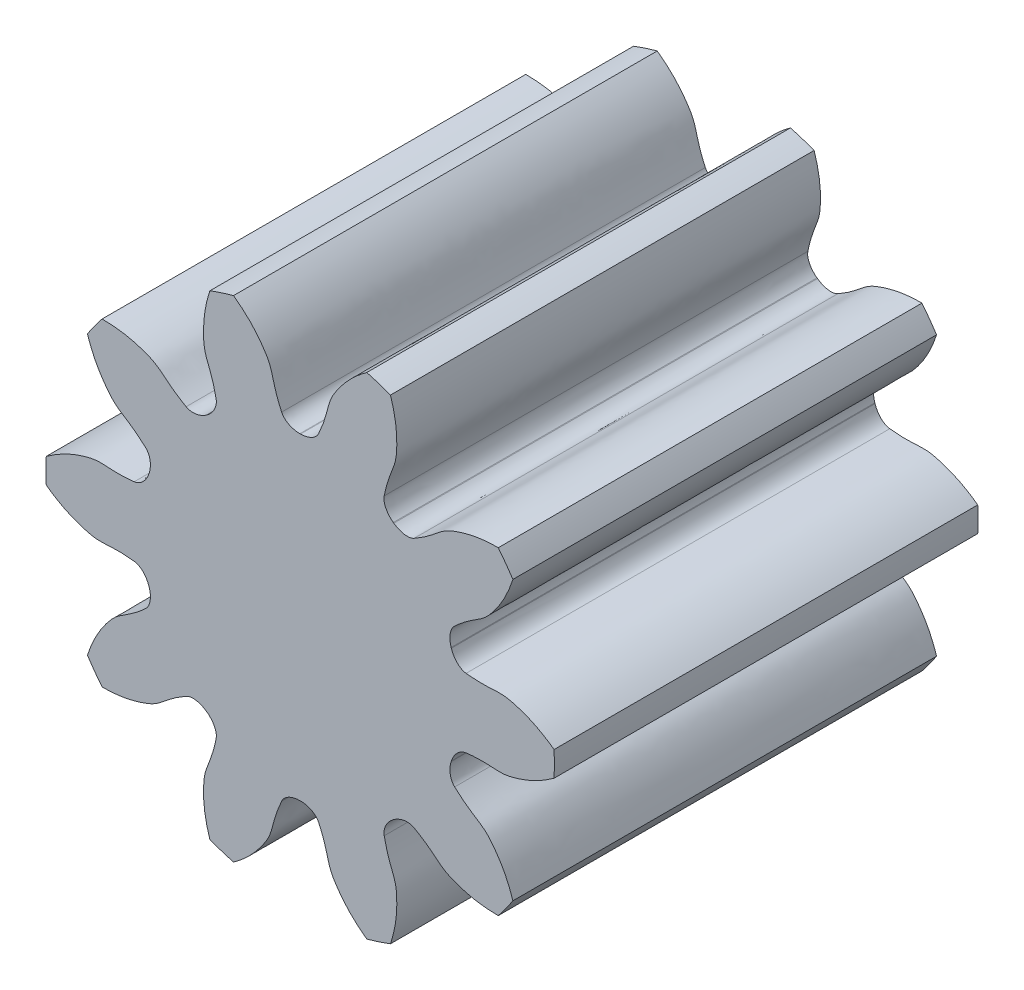
from build123d import *

# Parameters (mm, degrees)
ESQUISSE1_R         = 2.4
BOSS_EXTRU_1_DEPTH  = 4
CREUX_DE_DENT_DEPTH = 4
DENTURE_COUNT       = 10


with BuildPart() as part:
    # Esquisse1 → Boss.-Extru.1 (new body)
    with BuildSketch(Plane.XY):
        Circle(ESQUISSE1_R)
    extrude(amount=BOSS_EXTRU_1_DEPTH)

    # Profil dent → Creux de dent (cut)
    with BuildSketch(Plane.XY.offset(4)):
        with BuildLine():
            ThreePointArc((0.00314159, 1.49999671), (0, 1.5), (-0.00314159, 1.49999671))
            add(Edge.make_bspline(
                [(-0.174783658, 1.590424683), (-0.146609107, 1.530004164), (-0.069808111, 1.499857084), (-0.00314159, 1.49999671)],
                knots=[0, 0, 0, 0, 1, 1, 1, 1], degree=3))
            add(Edge.make_bspline(
                [(-0.649791541, 2.331130831), (-0.577205252, 2.279286461), (-0.456857798, 2.182492765), (-0.307065131, 1.979604877), (-0.262365622, 1.862358121), (-0.23113276, 1.711265721), (-0.174783658, 1.590424683)],
                knots=[0, 0, 0, 0, 0.31446368, 0.566482113, 0.749017728, 1, 1, 1, 1], degree=3))
            ThreePointArc((-0.649791541, 2.331130831), (0, 2.42), (0.649791541, 2.331130831))
            add(Edge.make_bspline(
                [(0.649791541, 2.331130831), (0.577205252, 2.279286461), (0.456857798, 2.182492765), (0.307065131, 1.979604877), (0.262365622, 1.862358121), (0.23113276, 1.711265721), (0.174783658, 1.590424683)],
                knots=[0, 0, 0, 0, 0.31446368, 0.566482113, 0.749017728, 1, 1, 1, 1], degree=3))
            add(Edge.make_bspline(
                [(0.174783658, 1.590424683), (0.146609107, 1.530004164), (0.069808111, 1.499857084), (0.00314159, 1.49999671)],
                knots=[0, 0, 0, 0, 1, 1, 1, 1], degree=3))
        make_face()
    creux_de_dent = extrude(amount=-CREUX_DE_DENT_DEPTH, mode=Mode.SUBTRACT)

    # Denture: Creux de dent ×10 about axis
    denture_axis = Axis((0, 0, -46), (0, 0, 1))
    for i in range(1, DENTURE_COUNT):
        add(creux_de_dent.rotate(denture_axis, i * 360 / DENTURE_COUNT), mode=Mode.SUBTRACT)


solid = part.part
